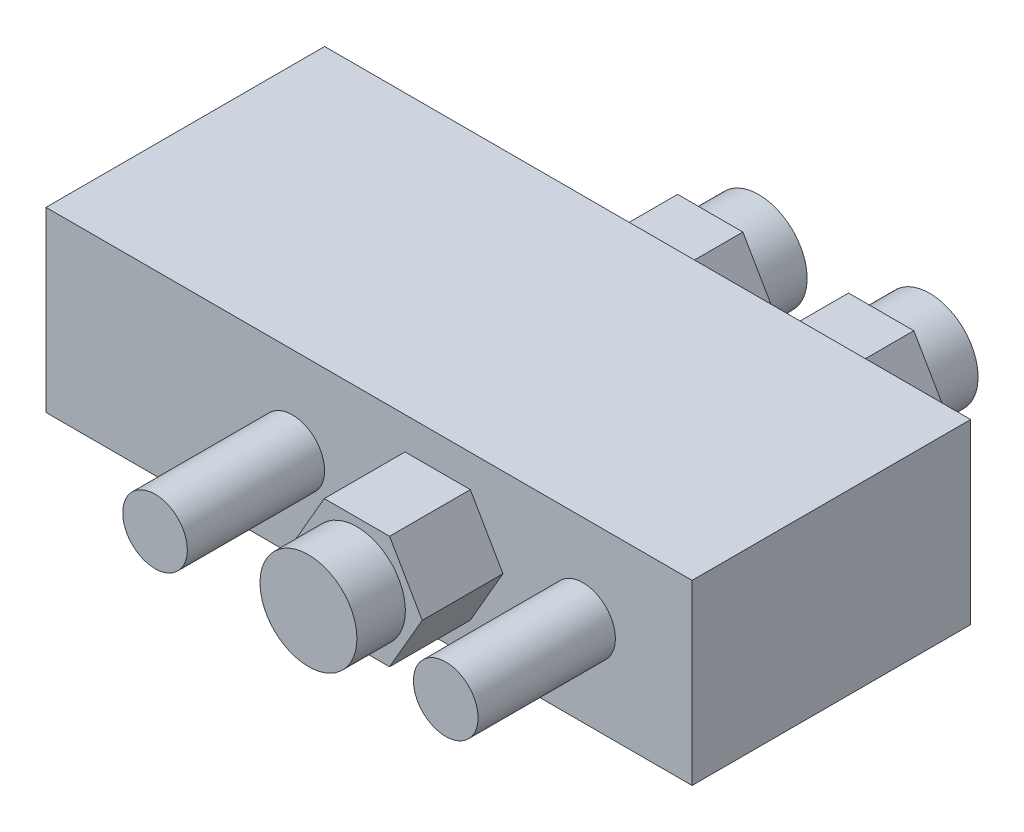
from build123d import *

# Parameters (mm, degrees)
SKETCH1_W           = 80
SKETCH1_H           = 34.5
BOSS_EXTRUDE1_DEPTH = 22
SKETCH2_R           = 4
BOSS_EXTRUDE2_DEPTH = 17
BOSS_EXTRUDE3_DEPTH = 10
BOSS_EXTRUDE6_DEPTH = 10
SKETCH7_R           = 6
BOSS_EXTRUDE7_DEPTH = 6
SKETCH8_R           = 6
BOSS_EXTRUDE8_DEPTH = 6


with BuildPart() as part:
    # Sketch1 → Boss-Extrude1 (new body)
    with BuildSketch(Plane(origin=(0, 0, 0), x_dir=(1, 0, 0), z_dir=(0, 1, 0))):
        with Locations((40, 17.25)):
            Rectangle(SKETCH1_W, SKETCH1_H)
    extrude(amount=BOSS_EXTRUDE1_DEPTH)

    # Sketch2 → Boss-Extrude2 (add)
    with BuildSketch(Plane.XY):
        with Locations((30.5, 11)):
            Circle(SKETCH2_R)
        with Locations((66.5, 11)):
            Circle(SKETCH2_R)
    extrude(amount=BOSS_EXTRUDE2_DEPTH)

    # Sketch3 → Boss-Extrude3 (add)
    with BuildSketch(Plane(origin=(0, 0, -34.5), x_dir=(-1, 0, 0), z_dir=(0, 0, -1))):
        Polygon((-50.834192463, 11), (-54.875644347, 18), (-62.958548116, 18), (-67, 11), (-62.958548116, 4), (-54.875644347, 4), align=None)
        Polygon((-29.668384925, 11), (-33.70983681, 18), (-41.792740578, 18), (-45.834192463, 11), (-41.792740578, 4), (-33.70983681, 4), align=None)
    extrude(amount=BOSS_EXTRUDE3_DEPTH)

    # Sketch6 → Boss-Extrude6 (add)
    with BuildSketch(Plane.XY):
        Polygon((56.582903769, 11), (52.541451884, 18), (44.458548116, 18), (40.417096231, 11), (44.458548116, 4), (52.541451884, 4), align=None)
    extrude(amount=BOSS_EXTRUDE6_DEPTH)

    # Sketch7 → Boss-Extrude7 (add)
    with BuildSketch(Plane.XY.offset(10)):
        with Locations((48.5, 11)):
            Circle(SKETCH7_R)
    extrude(amount=BOSS_EXTRUDE7_DEPTH)

    # Sketch8 → Boss-Extrude8 (add)
    with BuildSketch(Plane(origin=(0, 0, -44.5), x_dir=(-1, 0, 0), z_dir=(0, 0, -1))):
        with Locations((-58.917096231, 11)):
            Circle(SKETCH8_R)
        with Locations((-37.751288694, 11)):
            Circle(SKETCH8_R)
    extrude(amount=BOSS_EXTRUDE8_DEPTH)


solid = part.part
